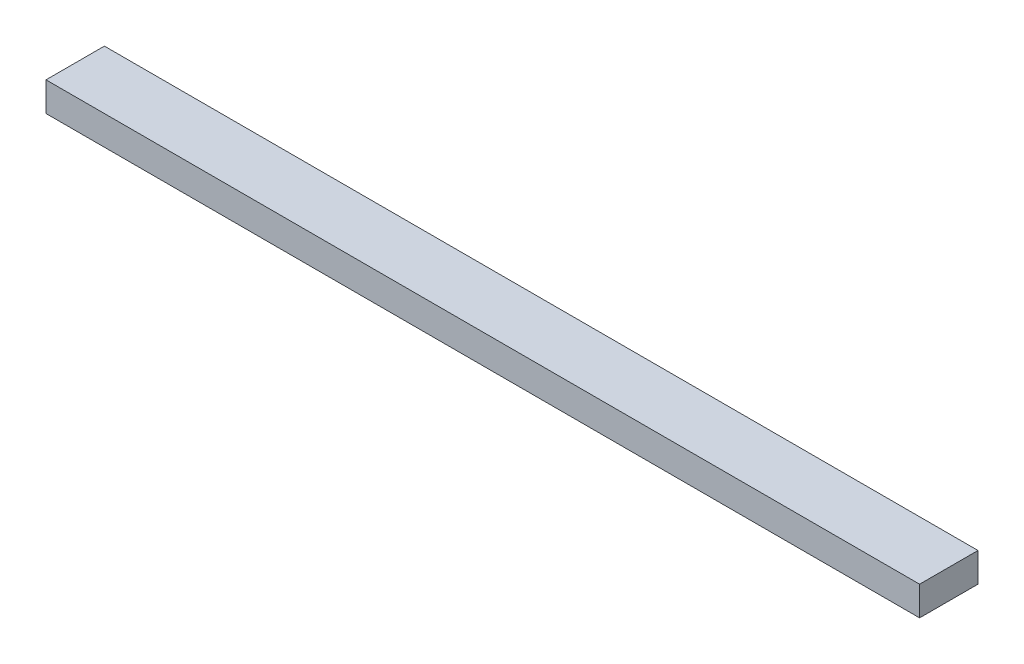
from build123d import *

# Parameters (mm, degrees)
SKETCH1_W           = 569.9125
SKETCH1_H           = 38.1
BOSS_EXTRUDE1_DEPTH = 19.05


with BuildPart() as part:
    # Sketch1 → Boss-Extrude1 (new body)
    with BuildSketch(Plane(origin=(0, 0, 0), x_dir=(1, 0, 0), z_dir=(0, 1, 0))):
        with Locations((284.95625, 19.05)):
            Rectangle(SKETCH1_W, SKETCH1_H)
    extrude(amount=BOSS_EXTRUDE1_DEPTH)


solid = part.part
